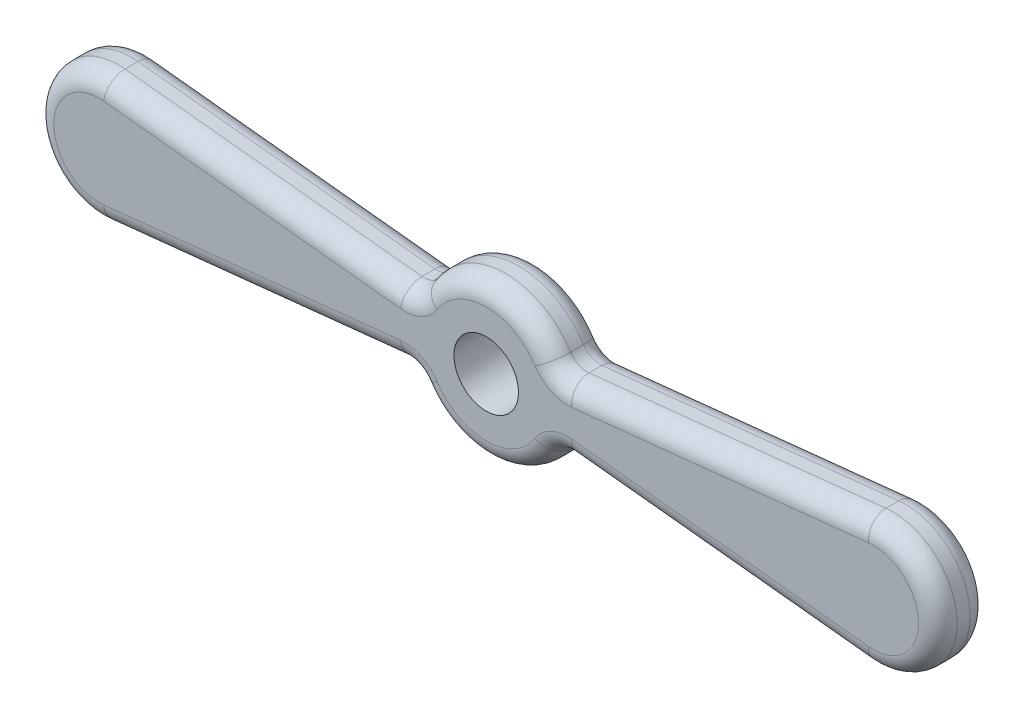
from build123d import *

# Parameters (mm, degrees)
SKETCH_1_R      = 5
EXTRUDE_1_DEPTH = 8
FILLET_1_R      = 3
FILLET_2_R      = 3
FILLET_3_R      = 3


with BuildPart() as part:
    # 草圖1 → 填料-伸長1 (new body)
    with BuildSketch(Plane.XY):
        with BuildLine():
            Line((58.954715367, 9.945218954), (10.953934927, 4.900133633))
            ThreePointArc((10.953934927, 4.900133633), (0, 12), (-10.953934927, 4.900133633))
            Line((-10.953934927, 4.900133633), (-58.954715367, 9.945218954))
            ThreePointArc((-58.954715367, 9.945218954), (-70, 0), (-58.954715367, -9.945218954))
            Line((-58.954715367, -9.945218954), (-10.953934927, -4.900133633))
            ThreePointArc((-10.953934927, -4.900133633), (0, -12), (10.953934927, -4.900133633))
            Line((10.953934927, -4.900133633), (58.954715367, -9.945218954))
            ThreePointArc((58.954715367, -9.945218954), (70, 0), (58.954715367, 9.945218954))
        make_face()
        Circle(SKETCH_1_R, mode=Mode.SUBTRACT)
    extrude(amount=EXTRUDE_1_DEPTH)

    # 圓角1
    fillet_1_edges = [part.edges().sort_by_distance(p)[0] for p in [
        (10.953934927, -4.900133633, 4),
        (-10.953934927, -4.900133633, 4),
        (-10.953934927, 4.900133633, 4),
        (10.953934927, 4.900133633, 4),
    ]]
    fillet(fillet_1_edges, radius=FILLET_1_R)

    # 圓角2
    fillet_2_edges = [part.edges().sort_by_distance(p)[0] for p in [
        (-70, 0, 8),
        (-35.948953134, -7.527215907, 8),
        (-35.948953134, 7.527215907, 8),
        (0, 12, 8),
        (0, -12, 8),
        (35.948953134, -7.527215907, 8),
        (-11.32982846, 5.388970193, 8),
        (-11.32982846, -5.388970193, 8),
        (11.32982846, -5.388970193, 8),
        (11.32982846, 5.388970193, 8),
        (70, 0, 8),
        (35.948953134, 7.527215907, 8),
    ]]
    fillet(fillet_2_edges, radius=FILLET_2_R)

    # 圓角3
    fillet_3_edges = [part.edges().sort_by_distance(p)[0] for p in [
        (35.948953134, 7.527215907, 0),
        (70, 0, 0),
        (-35.948953134, 7.527215907, 0),
        (0, 12, 0),
        (0, -12, 0),
        (35.948953134, -7.527215907, 0),
        (-11.32982846, 5.388970193, 0),
        (-11.32982846, -5.388970193, 0),
        (11.32982846, -5.388970193, 0),
        (11.32982846, 5.388970193, 0),
        (-35.948953134, -7.527215907, 0),
        (-70, 0, 0),
    ]]
    fillet(fillet_3_edges, radius=FILLET_3_R)


solid = part.part
